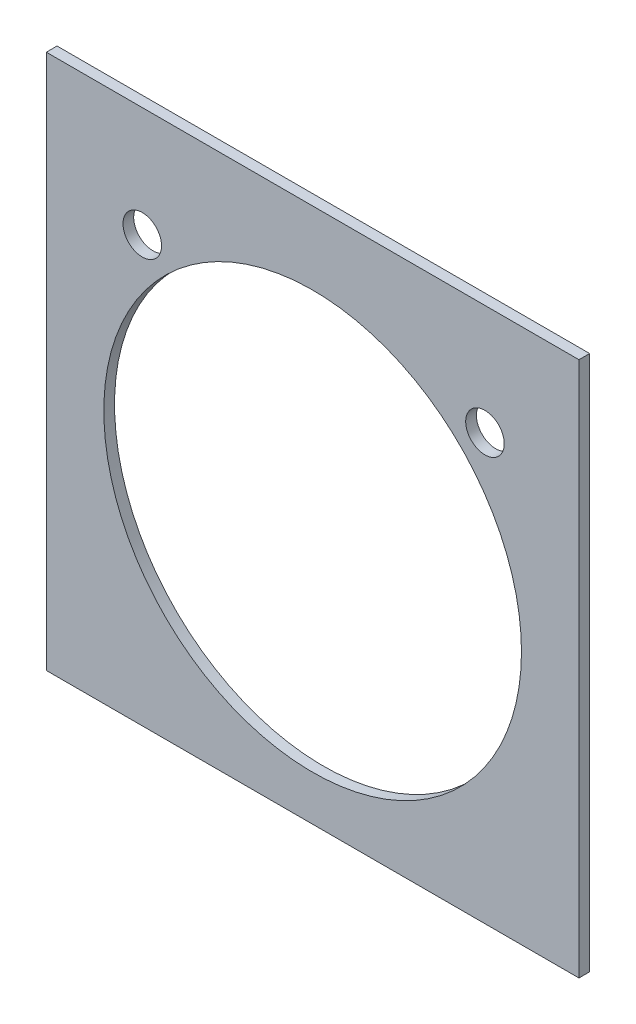
from build123d import *

# Parameters (mm, degrees)
SKETCH2_W           = 49.736379614
SKETCH2_H           = 50
BOSS_EXTRUDE2_DEPTH = 1
SKETCH3_R           = 19.5
CUT_EXTRUDE1_DEPTH  = 1
SKETCH6_R           = 1.8
CUT_EXTRUDE2_DEPTH  = 2


with BuildPart() as part:
    # Sketch2 → Boss-Extrude2 (new body)
    with BuildSketch(Plane.XY):
        Rectangle(SKETCH2_W, SKETCH2_H)
    extrude(amount=BOSS_EXTRUDE2_DEPTH)

    # Sketch3 → Cut-Extrude1 (cut)
    with BuildSketch(Plane.XY.offset(1)):
        with Locations((0, -1.3)):
            Circle(SKETCH3_R)
    extrude(amount=-CUT_EXTRUDE1_DEPTH, mode=Mode.SUBTRACT)

    # Sketch6 → Cut-Extrude2 (cut, through all)
    with BuildSketch(Plane.XY.offset(1)):
        with Locations((-15.908992298, 14.714110903)):
            Circle(SKETCH6_R)
        with Locations((16.091007702, 14.714110903)):
            Circle(SKETCH6_R)
    extrude(amount=-CUT_EXTRUDE2_DEPTH, mode=Mode.SUBTRACT)


solid = part.part
